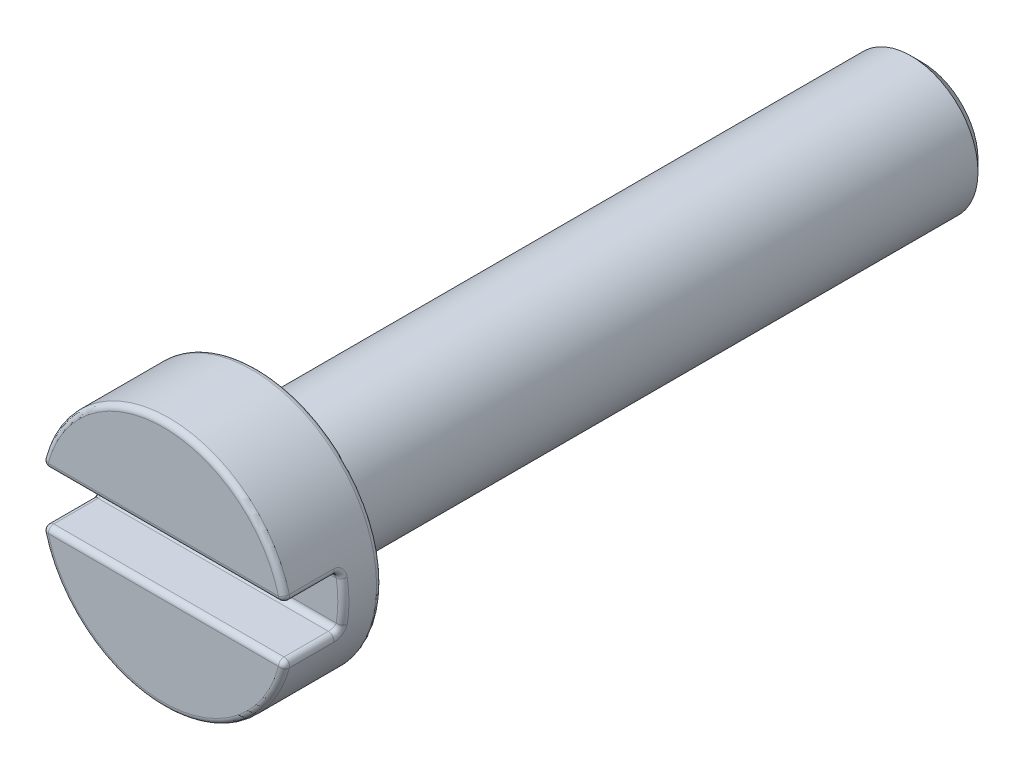
from build123d import *

# Parameters (mm, degrees)
SKIZZE2_W                       = 4.5
SKIZZE2_H                       = 0.9
SCHNITT_LINEAR_AUSTRAGEN1_DEPTH = 1
FASE1_SIZE                      = 0.2
VERRUNDUNG2_R                   = 0.1


with BuildPart() as part:
    # Skizze1 → Rotation1 (revolve)
    with BuildSketch(Plane(origin=(0, 0, 0), x_dir=(0, 0, -1), z_dir=(1, 0, 0))):
        Polygon((-1.7, 0), (-1.7, 2.25), (0, 2.25), (0, 1.21), (12, 1.21), (12, 0), align=None)
    revolve(axis=Axis((0, 0, 21.919879518), (0, 0, -1)))

    # Skizze2 → Schnitt-Linear austragen1 (cut)
    with BuildSketch(Plane.XY.offset(1.7)):
        Rectangle(SKIZZE2_W, SKIZZE2_H)
    extrude(amount=-SCHNITT_LINEAR_AUSTRAGEN1_DEPTH, mode=Mode.SUBTRACT)

    # Fase1
    fase1_edges = [part.edges().sort_by_distance(p)[0] for p in [
        (0, -1.21, -12),
    ]]
    chamfer(fase1_edges, length=FASE1_SIZE)

    # Verrundung2
    verrundung2_edges = [part.edges().sort_by_distance(p)[0] for p in [
        (1.423024947, 1.742842506, 1.7),
        (0, -2.25, 1.7),
        (2.25, 0, 0.7),
        (2.204540769, 0.45, 1.2),
        (2.204540769, -0.45, 1.2),
        (-2.25, 0, 0.7),
        (-2.204540769, 0.45, 1.2),
        (-2.204540769, -0.45, 1.2),
        (0, -0.45, 0.7),
        (0, 0.45, 0.7),
        (0, 0.45, 1.7),
        (0, -0.45, 1.7),
        (0, -2.25, 0),
    ]]
    fillet(verrundung2_edges, radius=VERRUNDUNG2_R)


solid = part.part
